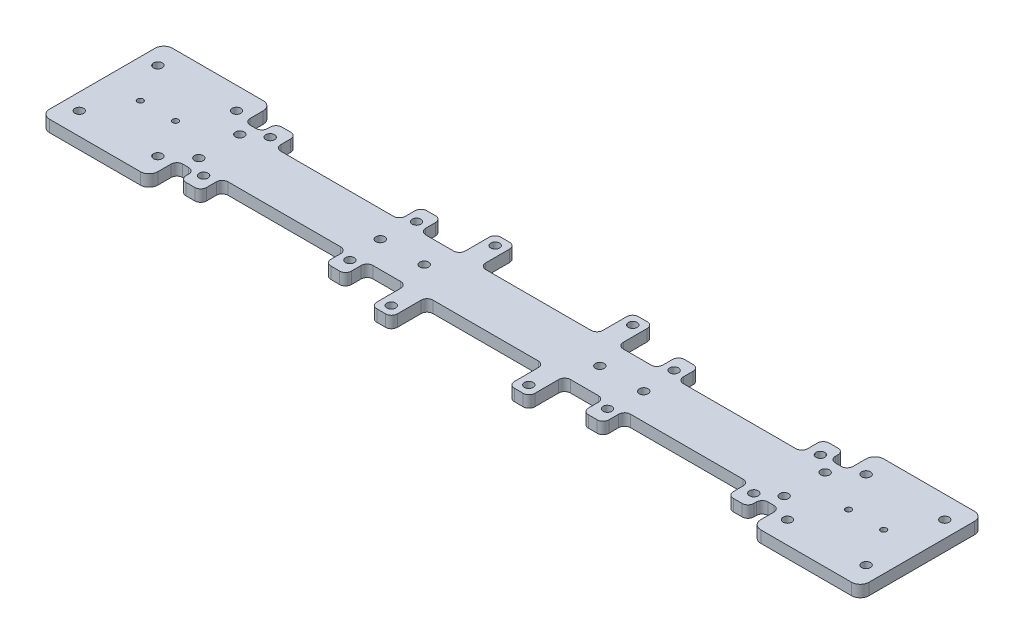
from build123d import *

# Parameters (mm, degrees)
SKETCH_1_W               = 280
SKETCH_1_H               = 42
EXTRUDE_1_DEPTH          = 4
SKETCH_2_R               = 1.5
SKETCH_2_R_2             = 1
CUT_EXTRUDE_1_DEPTH      = 5
SKETCH_4_R               = 1.5
CUT_EXTRUDE_2_DEPTH      = 5
SKETCH_5_W               = 180
SKETCH_5_H               = 23.948166932
CUT_EXTRUDE_3_DEPTH      = 5
SKETCH_6_R               = 1.5
CUT_EXTRUDE_4_DEPTH      = 5
SKETCH_7_W               = 7
SKETCH_7_H               = 10
SKETCH_7_R               = 1.5
EXTRUDE_2_DEPTH          = 4
SKETCH_9_W               = 7
SKETCH_9_H               = 24.323634809
SKETCH_9_R               = 1.5
EXTRUDE_3_DEPTH          = 4
SKETCH_12_W              = 8.321539138
SKETCH_12_H              = 9.046578038
CUT_EXTRUDE_8_DEPTH      = 5
SKETCH_11_W              = 6
SKETCH_11_H              = 10.747329905
CUT_EXTRUDE_7_DEPTH      = 5
MIRROR_2_COPY_1_SKETCH_W = 8.321539138
MIRROR_2_COPY_1_SKETCH_H = 9.046578038
MIRROR_2_COPY_1_DEPTH    = 5
MIRROR_2_COPY_2_SKETCH_W = 6
MIRROR_2_COPY_2_SKETCH_H = 10.747329905
MIRROR_2_COPY_2_DEPTH    = 5
FILLET_1_R               = 3
FILLET_1_OF_MIRROR_1_R   = 3
FILLET_3_R               = 2
FILLET_3_OF_MIRROR_3_R   = 2
SKETCH_10_R              = 1.5
CUT_EXTRUDE_6_DEPTH      = 5
FILLET_6_R               = 2
FILLET_7_R               = 2
FILLET_8_R               = 2
FILLET_9_R               = 2


with BuildPart() as part:
    # 草图1 → 凸台-拉伸1 (new body)
    with BuildSketch(Plane(origin=(0, 0, 0), x_dir=(1, 0, 0), z_dir=(0, 1, 0))):
        Rectangle(SKETCH_1_W, SKETCH_1_H)
    extrude(amount=EXTRUDE_1_DEPTH)

    # 草图2 → 切除-拉伸1 (cut, through all)
    with BuildSketch(Plane(origin=(0, 4, 0), x_dir=(1, 0, 0), z_dir=(0, 1, 0))):
        with Locations((-134.435028843, 13.435028843)):
            Circle(SKETCH_2_R)
        with Locations((-107.564971157, 13.435028843)):
            Circle(SKETCH_2_R)
        with Locations((-107.564971157, -13.435028843)):
            Circle(SKETCH_2_R)
        with Locations((-134.435028843, -13.435028843)):
            Circle(SKETCH_2_R)
        with Locations((-127, 0)):
            Circle(SKETCH_2_R_2)
        with Locations((-115, 0)):
            Circle(SKETCH_2_R_2)
    cut_extrude_1 = extrude(amount=-CUT_EXTRUDE_1_DEPTH, mode=Mode.SUBTRACT)

    # 草图4 → 切除-拉伸2 (cut, through all)
    with BuildSketch(Plane(origin=(0, 4, 0), x_dir=(1, 0, 0), z_dir=(0, 1, 0))):
        with Locations((-100, 7)):
            Circle(SKETCH_4_R)
        with Locations((-100, -7)):
            Circle(SKETCH_4_R)
    cut_extrude_2 = extrude(amount=-CUT_EXTRUDE_2_DEPTH, mode=Mode.SUBTRACT)

    # 草图5 → 切除-拉伸3 (cut, through all)
    with BuildSketch(Plane(origin=(0, 4, 0), x_dir=(1, 0, 0), z_dir=(0, 1, 0))):
        with Locations((0, 21)):
            Rectangle(SKETCH_5_W, SKETCH_5_H)
    cut_extrude_3 = extrude(amount=-CUT_EXTRUDE_3_DEPTH, mode=Mode.SUBTRACT)

    # 草图6 → 切除-拉伸4 (cut, through all)
    with BuildSketch(Plane(origin=(0, 4, 0), x_dir=(1, 0, 0), z_dir=(0, 1, 0))):
        with Locations((-94, 11.375)):
            Circle(SKETCH_6_R)
        with Locations((-94, -11.375)):
            Circle(SKETCH_6_R)
    cut_extrude_4 = extrude(amount=-CUT_EXTRUDE_4_DEPTH, mode=Mode.SUBTRACT)

    # 草图7 → 凸台-拉伸2 (add)
    with BuildSketch(Plane(origin=(0, 4, 0), x_dir=(1, 0, 0), z_dir=(0, 1, 0))):
        with Locations((-44, 11.375)):
            Rectangle(SKETCH_7_W, SKETCH_7_H)
        with Locations((-44, 11.375)):
            Circle(SKETCH_7_R, mode=Mode.SUBTRACT)
        with Locations((44, 11.375)):
            Rectangle(SKETCH_7_W, SKETCH_7_H)
        with Locations((44, 11.375)):
            Circle(SKETCH_7_R, mode=Mode.SUBTRACT)
    extrude_2 = extrude(amount=-EXTRUDE_2_DEPTH)

    # 草图9 → 凸台-拉伸3 (add)
    with BuildSketch(Plane(origin=(0, 4, 0), x_dir=(1, 0, 0), z_dir=(0, 1, 0))):
        with Locations((23.5, 9.025916535)):
            Rectangle(SKETCH_9_W, SKETCH_9_H)
        with Locations((23.5, 17.75)):
            Circle(SKETCH_9_R, mode=Mode.SUBTRACT)
        with Locations((-23.5, 9.025916535)):
            Rectangle(SKETCH_9_W, SKETCH_9_H)
        with Locations((-23.5, 17.75)):
            Circle(SKETCH_9_R, mode=Mode.SUBTRACT)
    extrude_3 = extrude(amount=-EXTRUDE_3_DEPTH)

    # 草图12 → 切除-拉伸8 (cut, through all)
    with BuildSketch(Plane(origin=(0, 4, 0), x_dir=(1, 0, 0), z_dir=(0, 1, 0))):
        with Locations((-94.160769569, 20.898289019)):
            Rectangle(SKETCH_12_W, SKETCH_12_H)
    cut_extrude_8 = extrude(amount=-CUT_EXTRUDE_8_DEPTH, mode=Mode.SUBTRACT)

    # 草图11 → 切除-拉伸7 (cut, through all)
    with BuildSketch(Plane(origin=(0, 4, 0), x_dir=(1, 0, 0), z_dir=(0, 1, 0))):
        with Locations((-100, 16.895612564)):
            Rectangle(SKETCH_11_W, SKETCH_11_H)
    cut_extrude_7 = extrude(amount=-CUT_EXTRUDE_7_DEPTH, mode=Mode.SUBTRACT)

    # 镜向4: 切除-拉伸8, 切除-拉伸7 across plane
    add(cut_extrude_8.mirror(Plane(origin=(0, 0, 0), x_dir=(0, 0, 1), z_dir=(1, 0, 0))), mode=Mode.SUBTRACT)
    add(cut_extrude_7.mirror(Plane(origin=(0, 0, 0), x_dir=(0, 0, 1), z_dir=(1, 0, 0))), mode=Mode.SUBTRACT)

    # 镜向2: 切除-拉伸3, 切除-拉伸8, 切除-拉伸7 across plane
    add(cut_extrude_3.mirror(Plane.XY), mode=Mode.SUBTRACT)
    add(cut_extrude_8.mirror(Plane.XY), mode=Mode.SUBTRACT)
    add(cut_extrude_7.mirror(Plane.XY), mode=Mode.SUBTRACT)

    # 镜向2 copy 1 sketch → 镜向2 copy 1 (cut, through all)
    with BuildSketch(Plane(origin=(0, 4, 0), x_dir=(-1, 0, 0), z_dir=(0, 1, 0))):
        with Locations((-94.160769569, 20.898289019)):
            Rectangle(MIRROR_2_COPY_1_SKETCH_W, MIRROR_2_COPY_1_SKETCH_H)
    extrude(amount=-MIRROR_2_COPY_1_DEPTH, mode=Mode.SUBTRACT)

    # 镜向2 copy 2 sketch → 镜向2 copy 2 (cut, through all)
    with BuildSketch(Plane(origin=(0, 4, 0), x_dir=(-1, 0, 0), z_dir=(0, 1, 0))):
        with Locations((-100, 16.895612564)):
            Rectangle(MIRROR_2_COPY_2_SKETCH_W, MIRROR_2_COPY_2_SKETCH_H)
    extrude(amount=-MIRROR_2_COPY_2_DEPTH, mode=Mode.SUBTRACT)

    # 圆角1
    fillet_1_edges = [part.edges().sort_by_distance(p)[0] for p in [
        (-103, 2, -21),
        (-103, 2, 21),
        (-140, 2, -21),
        (-140, 2, 21),
    ]]
    fillet(fillet_1_edges, radius=FILLET_1_R)

    # 镜向1: 切除-拉伸1, 切除-拉伸2, 切除-拉伸4 across plane
    add(cut_extrude_1.mirror(Plane(origin=(0, 0, 0), x_dir=(0, 0, 1), z_dir=(1, 0, 0))), mode=Mode.SUBTRACT)
    add(cut_extrude_2.mirror(Plane(origin=(0, 0, 0), x_dir=(0, 0, 1), z_dir=(1, 0, 0))), mode=Mode.SUBTRACT)
    add(cut_extrude_4.mirror(Plane(origin=(0, 0, 0), x_dir=(0, 0, 1), z_dir=(1, 0, 0))), mode=Mode.SUBTRACT)

    # 圆角1 of 镜向1
    fillet_1_of_mirror_1_edges = [part.edges().sort_by_distance(p)[0] for p in [
        (103, 2, -21),
        (103, 2, 21),
        (140, 2, -21),
        (140, 2, 21),
    ]]
    fillet(fillet_1_of_mirror_1_edges, radius=FILLET_1_OF_MIRROR_1_R)

    # 圆角3
    fillet_3_edges = [part.edges().sort_by_distance(p)[0] for p in [
        (47.5, 2, -16.375),
        (40.5, 2, -16.375),
        (27, 2, -21.187733939),
        (20, 2, -21.187733939),
        (-20, 2, -21.187733939),
        (-27, 2, -21.187733939),
        (-40.5, 2, -16.375),
        (-47.5, 2, -16.375),
    ]]
    fillet(fillet_3_edges, radius=FILLET_3_R)

    # 镜向3: 凸台-拉伸2, 凸台-拉伸3 across plane
    add(extrude_2.mirror(Plane.XY))
    add(extrude_3.mirror(Plane.XY))

    # 圆角3 of 镜向3
    fillet_3_of_mirror_3_edges = [part.edges().sort_by_distance(p)[0] for p in [
        (47.5, 2, 16.375),
        (40.5, 2, 16.375),
        (27, 2, 21.187733939),
        (20, 2, 21.187733939),
        (-20, 2, 21.187733939),
        (-27, 2, 21.187733939),
        (-40.5, 2, 16.375),
        (-47.5, 2, 16.375),
    ]]
    fillet(fillet_3_of_mirror_3_edges, radius=FILLET_3_OF_MIRROR_3_R)

    # 草图10 → 切除-拉伸6 (cut, through all)
    with BuildSketch(Plane(origin=(0, 4, 0), x_dir=(1, 0, 0), z_dir=(0, 1, 0))):
        with Locations((-30, 0)):
            Circle(SKETCH_10_R)
        with Locations((-45, 0)):
            Circle(SKETCH_10_R)
        with Locations((30, 0)):
            Circle(SKETCH_10_R)
        with Locations((45, 0)):
            Circle(SKETCH_10_R)
    extrude(amount=-CUT_EXTRUDE_6_DEPTH, mode=Mode.SUBTRACT)

    # 圆角6
    fillet_6_edges = [part.edges().sort_by_distance(p)[0] for p in [
        (-90, 2, -16.375),
        (-97, 2, -16.375),
        (90, 2, -16.375),
        (97, 2, -16.375),
        (-90, 2, 16.375),
        (-97, 2, 16.375),
        (90, 2, 16.375),
        (97, 2, 16.375),
    ]]
    fillet(fillet_6_edges, radius=FILLET_6_R)

    # 圆角7
    fillet_7_edges = [part.edges().sort_by_distance(p)[0] for p in [
        (-103, 2, -11.521947611),
        (-97, 2, -11.521947611),
        (103, 2, -11.521947611),
        (97, 2, -11.521947611),
        (90, 2, 9.025916534),
        (-90, 2, 9.025916534),
        (-103, 2, 11.521947611),
        (-97, 2, 11.521947611),
        (103, 2, 11.521947611),
        (97, 2, 11.521947611),
        (-90, 2, -9.025916534),
        (90, 2, -9.025916534),
    ]]
    fillet(fillet_7_edges, radius=FILLET_7_R)

    # 圆角8
    fillet_8_edges = [part.edges().sort_by_distance(p)[0] for p in [
        (47.5, 2, -9.025916534),
        (40.5, 2, -9.025916534),
        (27, 2, -9.025916534),
        (20, 2, -9.025916534),
        (-20, 2, -9.025916534),
        (-27, 2, -9.025916534),
        (-47.5, 2, -9.025916534),
        (-40.5, 2, -9.025916534),
    ]]
    fillet(fillet_8_edges, radius=FILLET_8_R)

    # 圆角9
    fillet_9_edges = [part.edges().sort_by_distance(p)[0] for p in [
        (-40.5, 2, 9.025916534),
        (-47.5, 2, 9.025916534),
        (40.5, 2, 9.025916534),
        (47.5, 2, 9.025916534),
        (20, 2, 9.025916534),
        (27, 2, 9.025916534),
        (-27, 2, 9.025916534),
        (-20, 2, 9.025916534),
    ]]
    fillet(fillet_9_edges, radius=FILLET_9_R)


solid = part.part
